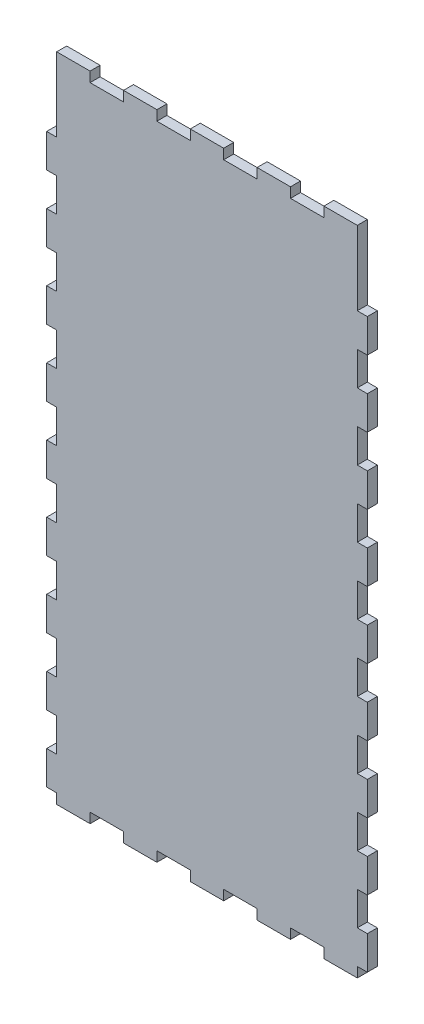
from build123d import *

# Parameters (mm, degrees)
ESQUISSE1_W                = 90
ESQUISSE1_H                = 189.15
BOSS_EXTRU_1_DEPTH         = 3
ESQUISSE2_W                = 10
ESQUISSE2_H                = 3
BOSS_EXTRU_2_DEPTH         = 3
R_P_TITION_LIN_AIRE1_COUNT = 5
R_P_TITION_LIN_AIRE1_PITCH = 20
ESQUISSE3_W                = 10
ESQUISSE3_H                = 3
BOSS_EXTRU_3_DEPTH         = 3
R_P_TITION_LIN_AIRE2_COUNT = 5
R_P_TITION_LIN_AIRE2_PITCH = 20
ESQUISSE4_W                = 3
ESQUISSE4_H                = 10
BOSS_EXTRU_4_DEPTH         = 3
R_P_TITION_LIN_AIRE3_COUNT = 9
R_P_TITION_LIN_AIRE3_PITCH = 20
ESQUISSE5_W                = 3
ESQUISSE5_H                = 10
BOSS_EXTRU_5_DEPTH         = 3
R_P_TITION_LIN_AIRE4_COUNT = 9
R_P_TITION_LIN_AIRE4_PITCH = 20


with BuildPart() as part:
    # Esquisse1 → Boss.-Extru.1 (new body)
    with BuildSketch(Plane.XY):
        with Locations((45, -94.575)):
            Rectangle(ESQUISSE1_W, ESQUISSE1_H)
    extrude(amount=BOSS_EXTRU_1_DEPTH)

    # Esquisse2 → Boss.-Extru.2 (add)
    with BuildSketch(Plane(origin=(0, 0, 0), x_dir=(1, 0, 0), z_dir=(0, 1, 0))):
        with Locations((5, -1.5)):
            Rectangle(ESQUISSE2_W, ESQUISSE2_H)
    boss_extru_2 = extrude(amount=BOSS_EXTRU_2_DEPTH)

    # Répétition linéaire1: Boss.-Extru.2 ×5
    with Locations(*[(i * R_P_TITION_LIN_AIRE1_PITCH, 0, 0) for i in range(1, R_P_TITION_LIN_AIRE1_COUNT)]):
        add(boss_extru_2)

    # Esquisse3 → Boss.-Extru.3 (add)
    with BuildSketch(Plane.XZ.offset(189.15)):
        with Locations((5, 1.5)):
            Rectangle(ESQUISSE3_W, ESQUISSE3_H)
    boss_extru_3 = extrude(amount=BOSS_EXTRU_3_DEPTH)

    # Répétition linéaire2: Boss.-Extru.3 ×5
    with Locations(*[(i * R_P_TITION_LIN_AIRE2_PITCH, 0, 0) for i in range(1, R_P_TITION_LIN_AIRE2_COUNT)]):
        add(boss_extru_3)

    # Esquisse4 → Boss.-Extru.4 (add)
    with BuildSketch(Plane.ZY):
        with Locations((1.5, -184.15)):
            Rectangle(ESQUISSE4_W, ESQUISSE4_H)
    boss_extru_4 = extrude(amount=BOSS_EXTRU_4_DEPTH)

    # Répétition linéaire3: Boss.-Extru.4 ×9
    with Locations(*[(0, i * R_P_TITION_LIN_AIRE3_PITCH, 0) for i in range(1, R_P_TITION_LIN_AIRE3_COUNT)]):
        add(boss_extru_4)

    # Esquisse5 → Boss.-Extru.5 (add)
    with BuildSketch(Plane(origin=(90, 0, 0), x_dir=(0, 0, -1), z_dir=(1, 0, 0))):
        with Locations((-1.5, -184.15)):
            Rectangle(ESQUISSE5_W, ESQUISSE5_H)
    boss_extru_5 = extrude(amount=BOSS_EXTRU_5_DEPTH)

    # Répétition linéaire4: Boss.-Extru.5 ×9
    with Locations(*[(0, i * R_P_TITION_LIN_AIRE4_PITCH, 0) for i in range(1, R_P_TITION_LIN_AIRE4_COUNT)]):
        add(boss_extru_5)


solid = part.part
